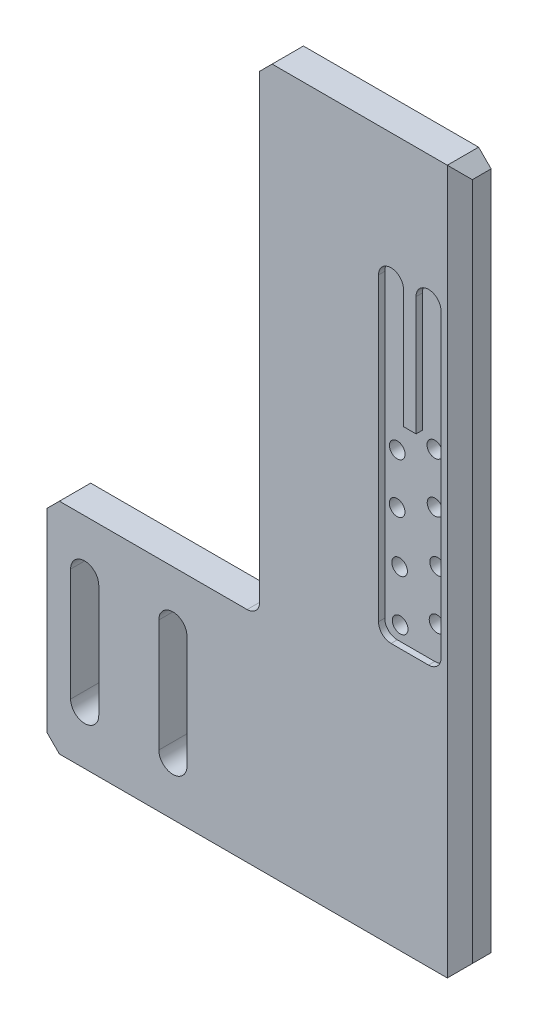
from build123d import *

# Parameters (mm, degrees)
BOSS_EXTRUDE1_DEPTH   = 5
CUT_EXTRUDE1_DEPTH    = 1
FILLET1_R             = 2
M3X0_5_TAPPED_HOLE1_D = 2.5
CHAMFER1_SIZE         = 2
FILLET2_R             = 2


with BuildPart() as part:
    # Sketch1 → Boss-Extrude1 (new body)
    with BuildSketch(Plane.XY):
        Polygon((-25, 62.939446367), (7, 62.939446367), (7, -49.560553633), (-59, -49.560553633), (-59, -14.560553633), (-25, -14.560553633), align=None)
        with BuildLine():
            Line((-55.209251079, -23.060553633), (-55.209251079, -41.060553633))
            ThreePointArc((-55.209251079, -41.060553633), (-52.959251079, -43.310553633), (-50.709251079, -41.060553633))
            Line((-50.709251079, -41.060553633), (-50.709251079, -23.060553633))
            ThreePointArc((-50.709251079, -23.060553633), (-52.959251079, -20.810553633), (-55.209251079, -23.060553633))
        make_face(mode=Mode.SUBTRACT)
        with BuildLine():
            Line((-41.108819931, -23.060553633), (-41.108819931, -41.060553633))
            ThreePointArc((-41.108819931, -41.060553633), (-38.858819931, -43.310553633), (-36.608819931, -41.060553633))
            Line((-36.608819931, -41.060553633), (-36.608819931, -23.060553633))
            ThreePointArc((-36.608819931, -23.060553633), (-38.858819931, -20.810553633), (-41.108819931, -23.060553633))
        make_face(mode=Mode.SUBTRACT)
    extrude(amount=BOSS_EXTRUDE1_DEPTH)

    # Sketch5 → Cut-Extrude1 (cut)
    with BuildSketch(Plane.XY.offset(5)):
        with BuildLine():
            Line((-2, 42.249819041), (-2, 23.249819041))
            Line((-2, 23.249819041), (0, 23.249819041))
            Line((0, 23.249819041), (0, 42.249819041))
            ThreePointArc((0, 42.249819041), (2, 44.249819041), (4, 42.249819041))
            Line((4, 42.249819041), (4, -7.750180959))
            Line((4, -7.750180959), (-6, -7.750180959))
            Line((-6, -7.750180959), (-6, 42.249819041))
            ThreePointArc((-6, 42.249819041), (-4, 44.249819041), (-2, 42.249819041))
        make_face()
    extrude(amount=-CUT_EXTRUDE1_DEPTH, mode=Mode.SUBTRACT)

    # Fillet1
    fillet1_edges = [part.edges().sort_by_distance(p)[0] for p in [
        (4, -7.750180959, 4.5),
        (-6, -7.750180959, 4.5),
    ]]
    fillet(fillet1_edges, radius=FILLET1_R)

    # M3x0.5 Tapped Hole1 (through all)
    with Locations(Plane.XY.offset(4)):
        with Locations((-4, 18.542431445), (2, 21.630678546), (2.034899716, 13.630754671), (-4.025360665, 10.542471642), (2.452029153, 5.630754671), (-3.630206533, 2.552236776), (2.358171393, -2.36869473), (-3.536291388, -5.447211951)):
            Hole(M3X0_5_TAPPED_HOLE1_D / 2)

    # Chamfer1
    chamfer1_edges = [part.edges().sort_by_distance(p)[0] for p in [
        (-25, 62.939446367, 2.5),
        (7, 62.939446367, 2.5),
        (7, -49.560553633, 2.5),
        (-59, -49.560553633, 2.5),
        (-59, -14.560553633, 2.5),
        (7, 6.689446367, 5),
    ]]
    chamfer(chamfer1_edges, length=CHAMFER1_SIZE)

    # Fillet2
    fillet2_edges = [part.edges().sort_by_distance(p)[0] for p in [
        (-25, -14.560553633, 2.5),
    ]]
    fillet(fillet2_edges, radius=FILLET2_R)


solid = part.part
